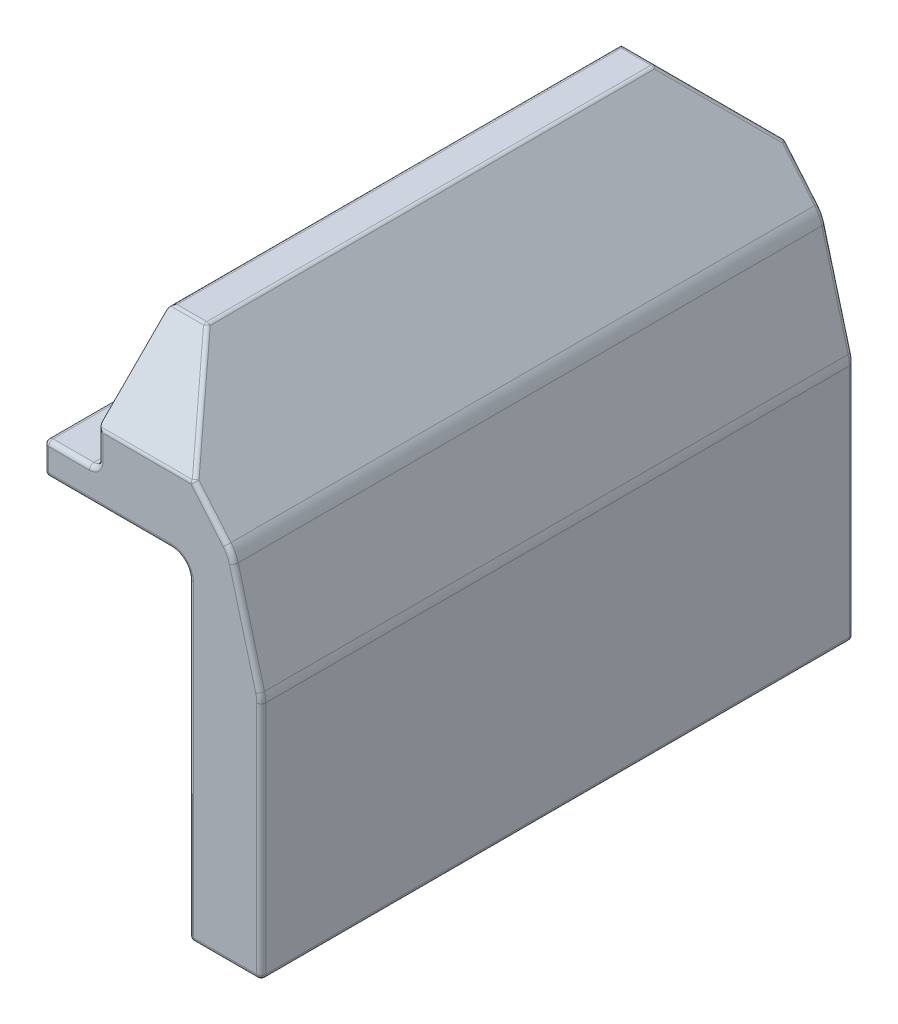
from build123d import *

# Parameters (mm, degrees)
SKETCH1_W                        = 76.2
SKETCH1_H                        = 165.1
EXTRUDE1_DEPTH                   = 103.98125
CUT_EXTRUDE2_REACH               = 228.968
SKETCH3_W                        = 50.8
SKETCH3_H                        = 115.8875
CUT_EXTRUDE6_REACH               = 228.968
CHAMFER1_SIZE                    = 25.4
FILLET5_R                        = 6.35
SHELL2_T                         = -6.35
BOSS_EXTRUDE1_REACH              = 200.801
SKETCH16_W                       = 12.7
SKETCH16_H                       = 6.35
F_17_64_0_26563_DIAMETER_HOLE3_D = 6.747002
FILLET1_R                        = 12.7
FILLET4_R                        = 1.5875


with BuildPart() as part:
    # Sketch1 → Extrude1 (new, symmetric)
    with BuildSketch(Plane.XY):
        Rectangle(SKETCH1_W, SKETCH1_H)
    extrude(amount=EXTRUDE1_DEPTH, both=True)

    # Sketch3 → Cut-Extrude2 (cut, up to next)
    with BuildSketch(Plane.XY.offset(103.98125), mode=Mode.PRIVATE) as cut_extrude2_sk1:
        with Locations((-12.7, -24.60625)):
            Rectangle(SKETCH3_W, SKETCH3_H)
    cut_extrude2_tool1 = extrude(cut_extrude2_sk1.sketch, amount=-CUT_EXTRUDE2_REACH, mode=Mode.PRIVATE) & part.part
    add(cut_extrude2_tool1.solids().sort_by_distance((-12.7, -24.60625, 103.98125))[0], mode=Mode.SUBTRACT)

    # Sketch10 → Cut-Extrude6 (cut, up to next)
    with BuildSketch(Plane.XY.offset(103.98125), mode=Mode.PRIVATE) as cut_extrude6_sk1:
        Polygon((-6.35, 82.55), (27.706904006, 41.962562299), (38.1, 3.175), (38.1, 82.55), align=None)
    cut_extrude6_tool1 = extrude(cut_extrude6_sk1.sketch, amount=-CUT_EXTRUDE6_REACH, mode=Mode.PRIVATE) & part.part
    # Sketch10 → Cut-Extrude6 (cut, up to next)
    with BuildSketch(Plane.XY.offset(103.98125), mode=Mode.PRIVATE) as cut_extrude6_sk2:
        with BuildLine():
            Line((-38.1, 44.45), (-22.225, 44.45))
            ThreePointArc((-22.225, 44.45), (-19.97993597, 45.37993597), (-19.05, 47.625))
            Line((-19.05, 47.625), (-19.05, 82.55))
            Line((-19.05, 82.55), (-38.1, 82.55))
            Line((-38.1, 82.55), (-38.1, 44.45))
        make_face()
    cut_extrude6_tool2 = extrude(cut_extrude6_sk2.sketch, amount=-CUT_EXTRUDE6_REACH, mode=Mode.PRIVATE) & part.part
    add(cut_extrude6_tool1.solids().sort_by_distance((24.468167, 60.718714, 103.98125))[0], mode=Mode.SUBTRACT)
    add(cut_extrude6_tool2.solids().sort_by_distance((-28.601355, 63.55483, 103.98125))[0], mode=Mode.SUBTRACT)

    # Chamfer1
    chamfer1_edges = [part.edges().sort_by_distance(p)[0] for p in [
        (-12.7, 82.55, -103.98125),
        (-12.7, 82.55, 103.98125),
    ]]
    chamfer(chamfer1_edges, length=CHAMFER1_SIZE)

    # Fillet5
    fillet5_edges = [part.edges().sort_by_distance(p)[0] for p in [
        (12.7, 33.3375, 0),
    ]]
    fillet(fillet5_edges, radius=FILLET5_R)

    # Shell2
    shell2_openings = [part.faces().sort_by_distance(p)[0] for p in [
        (25.4, -82.55, 0),
    ]]
    offset(amount=SHELL2_T, openings=shell2_openings)

    # Sketch16 → Boss-Extrude1 (add, up to next)
    with BuildSketch(Plane.XZ.offset(82.55), mode=Mode.PRIVATE) as boss_extrude1_sk1:
        with Locations((25.4, 0)):
            Rectangle(SKETCH16_W, SKETCH16_H)
    boss_extrude1_tool1 = extrude(boss_extrude1_sk1.sketch, amount=-BOSS_EXTRUDE1_REACH, mode=Mode.PRIVATE) - part.part
    add(boss_extrude1_tool1.solids().sort_by_distance((25.4, -82.55, 0))[0])

    # 17/64 (0.26563) Diameter Hole3 (through all)
    with Locations(Plane(origin=(0, 44.45, 0), x_dir=(1, 0, 0), z_dir=(0, 1, 0))):
        with Locations((-26.9875, 19.05), (-26.9875, -19.05)):
            Hole(F_17_64_0_26563_DIAMETER_HOLE3_D / 2)

    # Fillet1
    fillet1_edges = [part.edges().sort_by_distance(p)[0] for p in [
        (38.1, 3.175, 0),
        (27.706904006, 41.962562299, 0),
    ]]
    fillet(fillet1_edges, radius=FILLET1_R)

    # Fillet4
    fillet4_edges = [part.edges().sort_by_distance(p)[0] for p in [
        (19.05, -82.55, 50.403125),
        (31.75, -82.55, -50.403125),
        (25.4, -82.55, -3.175),
        (25.4, -82.55, 3.175),
        (-23.613999, 44.45, 19.05),
        (-23.613999, 33.3375, 19.05),
        (-23.613999, 44.45, -19.05),
        (-23.613999, 33.3375, -19.05),
        (25.4, -82.55, -103.98125),
        (33.051436385, 22.016495915, 103.98125),
        (27.433394365, 41.820182191, 103.98125),
        (37.991349739, 3.160695922, 103.98125),
        (33.051436385, 22.016495915, -103.98125),
        (20.430125921, 50.634688723, -103.98125),
        (27.433394365, 41.820182191, -103.98125),
        (37.991349739, 3.160695922, -103.98125),
        (25.4, -82.55, 103.98125),
        (-38.1, 33.3375, 0),
        (12.7, -82.55, 0),
        (12.7, -27.78125, 103.98125),
        (-15.875, 33.3375, -103.98125),
        (-38.1, 38.89375, -103.98125),
        (-38.1, 38.89375, 103.98125),
        (-38.1, 44.45, 0),
        (-30.1625, 44.45, 103.98125),
        (-19.97993597, 45.37993597, 103.98125),
        (-19.05, 52.3875, 103.98125),
        (-19.97993597, 45.37993597, -103.98125),
        (-30.1625, 44.45, -103.98125),
        (38.1, -40.52349336, 103.98125),
        (38.1, -40.52349336, -103.98125),
        (20.430125921, 50.634688723, 103.98125),
        (-2.043434684, 57.15, 103.98125),
        (-19.05, 52.3875, -103.98125),
        (-19.05, 82.55, 0),
        (-6.35, 82.55, 0),
        (-12.7, 82.55, -78.58125),
        (-12.7, 82.55, 78.58125),
        (4.306565316, 69.85, -91.28125),
        (4.306565316, 69.85, 91.28125),
        (-2.043434684, 57.15, -103.98125),
        (-15.875, 33.3375, 103.98125),
        (12.7, -27.78125, -103.98125),
        (10.840128061, 31.477628061, 103.98125),
        (10.840128061, 31.477628061, -103.98125),
        (38.1, -82.55, 0),
        (31.75, -82.55, 50.403125),
        (-12.7, 76.2, 0),
        (25.4, -82.55, -97.63125),
        (15.330256121, 35.967756121, 97.63125),
        (25.4, -82.55, 97.63125),
        (15.330256121, 35.967756121, -97.63125),
        (-5.304929073, 39.6875, -97.63125),
        (-5.304929073, 39.6875, 97.63125),
        (19.05, -27.78125, 97.63125),
        (19.05, -27.78125, -97.63125),
        (19.05, -82.55, -50.403125),
        (-16.959858145, 39.6875, 0),
    ]]
    fillet(fillet4_edges, radius=FILLET4_R)


solid = part.part
